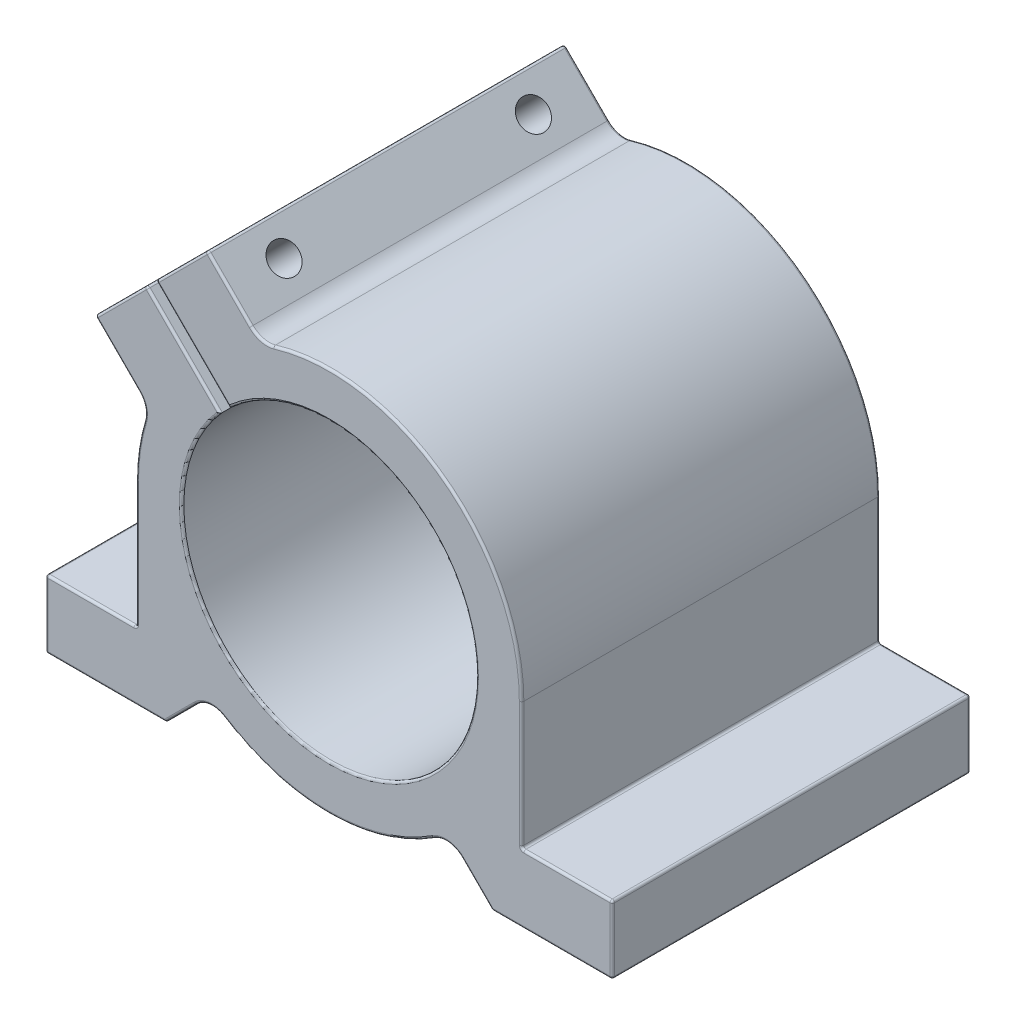
from build123d import *

# Parameters (mm, degrees)
EXTRUDE_1_DEPTH     = 39.5
FILLET_1_R          = 5
SKETCH_2_R          = 3.25
CUT_EXTRUDE_1_DEPTH = 19
SKETCH_3_R          = 2.1
CUT_EXTRUDE_2_DEPTH = 74.099765415
FILLET_2_R          = 0.5


with BuildPart() as part:
    # Эскиз1 → Бобышка-Вытянуть1 (new body, symmetric)
    with BuildSketch(Plane.XY):
        with BuildLine():
            Line((36, -43), (62.5, -43))
            Line((62.5, -43), (62.5, -28))
            Line((62.5, -28), (42.5, -28))
            Line((42.5, -28), (42.5, 0))
            ThreePointArc((42.5, 0), (38.249313664, -18.526737551), (26.347529211, -33.347529211))
            Line((26.347529211, -33.347529211), (36, -43))
        make_face()
        with BuildLine():
            ThreePointArc((-26.347529211, -33.347529211), (0, -42.5), (26.347529211, -33.347529211))
            ThreePointArc((26.347529211, -33.347529211), (38.249313664, -18.526737551), (42.5, 0))
            ThreePointArc((42.5, 0), (24.168680496, 34.958902773), (-15.011759204, 39.760496546))
            Line((-15.011759204, 39.760496546), (-6.99054806, 31.739285402))
            ThreePointArc((-6.99054806, 31.739285402), (20.359975295, 25.332220708), (32.5, 0))
            ThreePointArc((32.5, 0), (-3.515908449, -32.309261641), (-31.739285402, 6.99054806))
            Line((-31.739285402, 6.99054806), (-39.760496546, 15.011759204))
            ThreePointArc((-39.760496546, 15.011759204), (-41.809515085, 7.629839343), (-42.5, 0))
            ThreePointArc((-42.5, 0), (-38.249313664, -18.526737551), (-26.347529211, -33.347529211))
        make_face()
        with BuildLine():
            Line((-62.5, -43), (-36, -43))
            Line((-36, -43), (-26.347529211, -33.347529211))
            ThreePointArc((-26.347529211, -33.347529211), (-38.249313664, -18.526737551), (-42.5, 0))
            Line((-42.5, 0), (-42.5, -28))
            Line((-42.5, -28), (-62.5, -28))
            Line((-62.5, -28), (-62.5, -43))
        make_face()
        with BuildLine():
            Line((-6.99054806, 31.739285402), (-15.011759204, 39.760496546))
            ThreePointArc((-15.011759204, 39.760496546), (-22.415046614, 36.108388018), (-28.972654664, 31.093975007))
            Line((-28.972654664, 31.093975007), (-21.895820395, 24.017140738))
            ThreePointArc((-21.895820395, 24.017140738), (-14.950366222, 28.857175015), (-6.99054806, 31.739285402))
        make_face()
        with BuildLine():
            ThreePointArc((-31.093975007, 28.972654664), (-36.108388018, 22.415046614), (-39.760496546, 15.011759204))
            Line((-39.760496546, 15.011759204), (-31.739285402, 6.99054806))
            ThreePointArc((-31.739285402, 6.99054806), (-28.857175015, 14.950366222), (-24.017140738, 21.895820395))
            Line((-24.017140738, 21.895820395), (-31.093975007, 28.972654664))
        make_face()
        with BuildLine():
            Line((-51.594305205, 26.845567863), (-39.760496546, 15.011759204))
            ThreePointArc((-39.760496546, 15.011759204), (-36.108388018, 22.415046614), (-31.093975007, 28.972654664))
            Line((-31.093975007, 28.972654664), (-40.280596706, 38.159276362))
            Line((-40.280596706, 38.159276362), (-51.594305205, 26.845567863))
        make_face()
        with BuildLine():
            ThreePointArc((-28.972654664, 31.093975007), (-22.415046614, 36.108388018), (-15.011759204, 39.760496546))
            Line((-15.011759204, 39.760496546), (-26.845567863, 51.594305205))
            Line((-26.845567863, 51.594305205), (-38.159276362, 40.280596706))
            Line((-38.159276362, 40.280596706), (-28.972654664, 31.093975007))
        make_face()
    extrude(amount=EXTRUDE_1_DEPTH, both=True)

    # Скругление1
    fillet_1_edges = [part.edges().sort_by_distance(p)[0] for p in [
        (26.347529211, -33.347529211, 0),
        (-26.347529211, -33.347529211, 0),
        (-39.760496546, 15.011759204, 0),
        (-15.011759204, 39.760496546, 0),
    ]]
    fillet(fillet_1_edges, radius=FILLET_1_R)

    # Эскиз2 → Вырез-Вытянуть1 (cut)
    with BuildSketch(Plane(origin=(12.374368671, 12.374368671, 0), x_dir=(0, 0, -1), z_dir=(0.707106781, 0.707106781, 0))):
        with Locations((-27.5, 48.465366161)):
            Circle(SKETCH_2_R)
        with Locations((27.5, 48.465366161)):
            Circle(SKETCH_2_R)
    extrude(amount=-CUT_EXTRUDE_1_DEPTH, mode=Mode.SUBTRACT)

    # Эскиз3 → Вырез-Вытянуть2 (cut, through all)
    with BuildSketch(Plane(origin=(-1.060660172, -1.060660172, 0), x_dir=(0, 0, -1), z_dir=(0.707106781, 0.707106781, 0))):
        with Locations((-27.5, 48.465366161)):
            Circle(SKETCH_3_R)
        with Locations((27.5, 48.465366161)):
            Circle(SKETCH_3_R)
    extrude(amount=-CUT_EXTRUDE_2_DEPTH, mode=Mode.SUBTRACT)

    # Скругление2
    fillet_2_edges = [part.edges().sort_by_distance(p)[0] for p in [
        (-32.502422113, 45.937450955, 39.5),
        (52.5, -28, -39.5),
        (-30.027548378, 32.148868722, 39.5),
        (62.5, -35.5, -39.5),
        (49.25, -43, -39.5),
        (32.671223026, -39.671223026, -39.5),
        (-32.671223026, -39.671223026, -39.5),
        (-49.25, -43, -39.5),
        (-62.5, -35.5, -39.5),
        (-52.5, -28, -39.5),
        (-42.5, -14, -39.5),
        (22.980970389, -22.980970389, 39.5),
        (-45.937450955, 32.502422113, -39.5),
        (-32.148868722, 30.027548378, -39.5),
        (22.980970389, -22.980970389, -39.5),
        (-30.027548378, 32.148868722, -39.5),
        (-32.502422113, 45.937450955, -39.5),
        (25.361500244, 34.10343539, -39.5),
        (42.5, -14, -39.5),
        (-32.148868722, 30.027548378, 39.5),
        (-45.937450955, 32.502422113, 39.5),
        (42.5, -28, 0),
        (62.5, -28, 0),
        (62.5, -43, 0),
        (36, -43, 0),
        (-36, -43, 0),
        (-62.5, -43, 0),
        (-62.5, -28, 0),
        (-42.5, -28, 0),
        (-51.594305205, 26.845567863, 0),
        (-40.280596706, 38.159276362, 0),
        (-38.159276362, 40.280596706, 0),
        (-26.845567863, 51.594305205, 0),
        (42.5, -14, 39.5),
        (-42.5, -14, 39.5),
        (-52.5, -28, 39.5),
        (-62.5, -35.5, 39.5),
        (-49.25, -43, 39.5),
        (0, -42.5, -39.5),
        (0, -42.5, 39.5),
        (-32.671223026, -39.671223026, 39.5),
        (-42.048059229, 6.181481623, -39.5),
        (-42.048059229, 6.181481623, 39.5),
        (-46.774536395, 22.025799054, -39.5),
        (-46.774536395, 22.025799054, 39.5),
        (-22.025799054, 46.774536395, -39.5),
        (-22.025799054, 46.774536395, 39.5),
        (26.333511807, -34.905788007, -39.5),
        (32.671223026, -39.671223026, 39.5),
        (26.333511807, -34.905788007, 39.5),
        (-26.333511807, -34.905788007, -39.5),
        (-26.333511807, -34.905788007, 39.5),
        (-40.641725974, 14.891690607, -39.5),
        (49.25, -43, 39.5),
        (-40.641725974, 14.891690607, 39.5),
        (-14.891690607, 40.641725974, -39.5),
        (-14.891690607, 40.641725974, 39.5),
        (62.5, -35.5, 39.5),
        (25.361500244, 34.10343539, 39.5),
        (52.5, -28, 39.5),
    ]]
    fillet(fillet_2_edges, radius=FILLET_2_R)


solid = part.part
